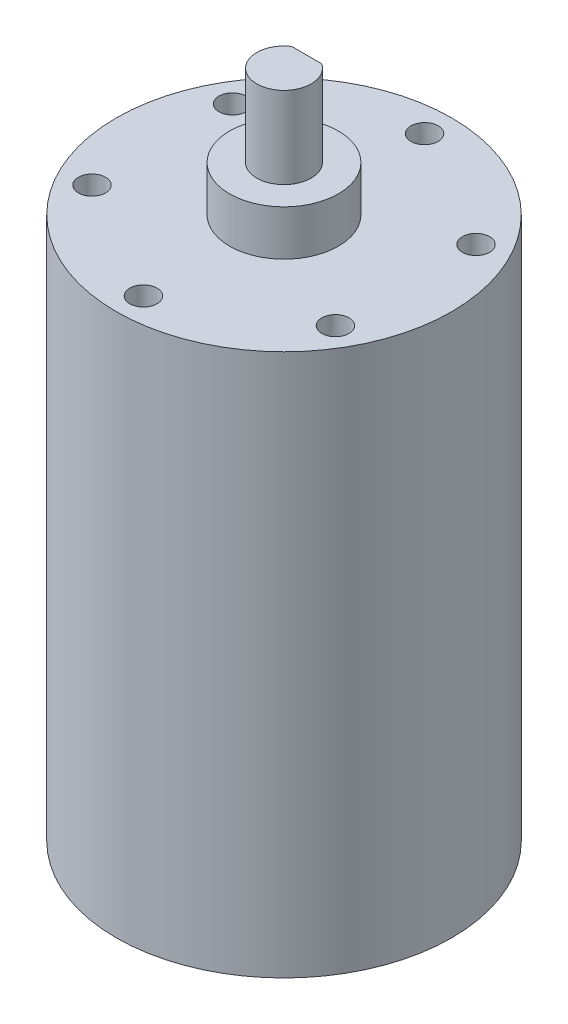
from build123d import *

# Parameters (mm, degrees)
SKETCH1_R           = 18.5
BOSS_EXTRUDE1_DEPTH = 59.8
SKETCH2_R           = 6
BOSS_EXTRUDE2_DEPTH = 5
BOSS_EXTRUDE3_DEPTH = 14
SKETCH2_5_R         = 1.5
CUT_EXTRUDE1_DEPTH  = 5


with BuildPart() as part:
    # Sketch1 → Boss-Extrude1 (new body)
    with BuildSketch(Plane(origin=(0, 0, 0), x_dir=(1, 0, 0), z_dir=(0, 1, 0))):
        Circle(SKETCH1_R)
    extrude(amount=BOSS_EXTRUDE1_DEPTH)

    # Sketch2 → Boss-Extrude2 (add)
    with BuildSketch(Plane(origin=(0, 59.8, 0), x_dir=(1, 0, 0), z_dir=(0, 1, 0))):
        Circle(SKETCH2_R)
    extrude(amount=BOSS_EXTRUDE2_DEPTH)

    # Sketch2_3 → Boss-Extrude3 (add)
    with BuildSketch(Plane(origin=(0, 59.8, 0), x_dir=(1, 0, 0), z_dir=(0, 1, 0))):
        with BuildLine():
            Line((1.658312395, 2.5), (-1.658312395, 2.5))
            ThreePointArc((-1.658312395, 2.5), (-1.418637165, -2.643382037), (3, 0))
            ThreePointArc((3, 0), (2.643382037, 1.418637165), (1.658312395, 2.5))
        make_face()
    extrude(amount=BOSS_EXTRUDE3_DEPTH)

    # Sketch2_5 → Cut-Extrude1 (cut)
    with BuildSketch(Plane(origin=(0, 59.8, 0), x_dir=(1, 0, 0), z_dir=(0, 1, 0))):
        with Locations((0, 15.5)):
            Circle(SKETCH2_5_R)
        with Locations((13.423393759, 7.75)):
            Circle(SKETCH2_5_R)
        with Locations((13.423393759, -7.75)):
            Circle(SKETCH2_5_R)
        with Locations((0, -15.5)):
            Circle(SKETCH2_5_R)
        with Locations((-13.423393759, -7.75)):
            Circle(SKETCH2_5_R)
        with Locations((-13.423393759, 7.75)):
            Circle(SKETCH2_5_R)
    extrude(amount=-CUT_EXTRUDE1_DEPTH, mode=Mode.SUBTRACT)


solid = part.part
